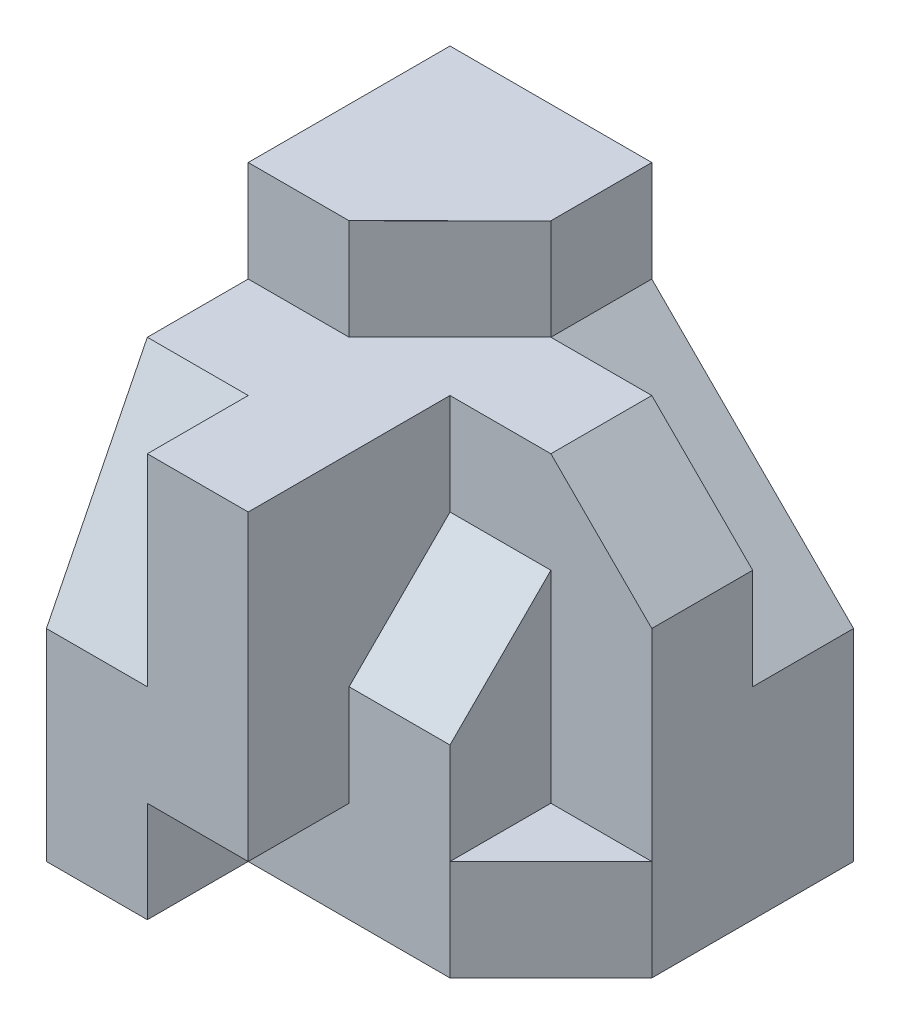
from build123d import *

# Parameters (mm, degrees)
SKETCH1_W           = 4
SKETCH1_H           = 5
BOSS_EXTRUDE1_DEPTH = 4
SKETCH2_OUTSIDE_W   = 7.51
SKETCH2_OUTSIDE_H   = 7.51
CUT_EXTRUDE1_DEPTH  = 1
CUT_EXTRUDE2_DEPTH  = 1
CUT_EXTRUDE3_DEPTH  = 1
CUT_EXTRUDE4_DEPTH  = 5
CUT_EXTRUDE5_DEPTH  = 1
SKETCH7_W           = 2
SKETCH7_H           = 1
CUT_EXTRUDE6_DEPTH  = 1
CUT_EXTRUDE7_DEPTH  = 2
SKETCH9_W           = 1
SKETCH9_H           = 1
CUT_EXTRUDE9_DEPTH  = 3
CUT_EXTRUDE10_DEPTH = 3


with BuildPart() as part:
    # Sketch1 → Boss-Extrude1 (new body)
    with BuildSketch(Plane.XY):
        Rectangle(SKETCH1_W, SKETCH1_H)
    extrude(amount=BOSS_EXTRUDE1_DEPTH)

    # Sketch2 outside → Cut-Extrude1 (cut)
    with BuildSketch(Plane(origin=(0, 2.5, 0), x_dir=(1, 0, 0), z_dir=(0, 1, 0))):
        with Locations((0, -2)):
            Rectangle(SKETCH2_OUTSIDE_W, SKETCH2_OUTSIDE_H)
        Polygon((0, 0), (0, -1), (-1, -2), (-2, -2), (-2, 0), align=None, mode=Mode.SUBTRACT)
    extrude(amount=-CUT_EXTRUDE1_DEPTH, mode=Mode.SUBTRACT)

    # Sketch3 → Cut-Extrude2 (cut)
    with BuildSketch(Plane(origin=(0, 0, 0), x_dir=(-1, 0, 0), z_dir=(0, 0, -1))):
        Polygon((0, 1.5), (-2, -0.5), (-2, 1.5), align=None)
    extrude(amount=-CUT_EXTRUDE2_DEPTH, mode=Mode.SUBTRACT)

    # Sketch4 → Cut-Extrude3 (cut)
    with BuildSketch(Plane.ZY.offset(2)):
        Polygon((3, 1.5), (4, -0.5), (4, 1.5), align=None)
    extrude(amount=-CUT_EXTRUDE3_DEPTH, mode=Mode.SUBTRACT)

    # Sketch5 → Cut-Extrude4 (cut, through all)
    with BuildSketch(Plane.XY.offset(4)):
        Polygon((2, 1.5), (1, 1.5), (2, 0.5), align=None)
    extrude(amount=-CUT_EXTRUDE4_DEPTH, mode=Mode.SUBTRACT)

    # Sketch6 → Cut-Extrude5 (cut)
    with BuildSketch(Plane.XY.offset(4)):
        Polygon((-1, -2.5), (-1, -1.5), (0, -1.5), (0, 1.5), (1, 1.5), (2, 0.5), (2, -2.5), align=None)
    extrude(amount=-CUT_EXTRUDE5_DEPTH, mode=Mode.SUBTRACT)

    # Sketch7 → Cut-Extrude6 (cut)
    with BuildSketch(Plane(origin=(0, 1.5, 0), x_dir=(1, 0, 0), z_dir=(0, 1, 0))):
        with Locations((1, -2.5)):
            Rectangle(SKETCH7_W, SKETCH7_H)
    extrude(amount=-CUT_EXTRUDE6_DEPTH, mode=Mode.SUBTRACT)

    # Sketch8 → Cut-Extrude7 (cut)
    with BuildSketch(Plane(origin=(2, 0, 0), x_dir=(0, 0, -1), z_dir=(1, 0, 0))):
        Polygon((-2, 0.5), (-3, -0.5), (-3, 0.5), align=None)
    extrude(amount=-CUT_EXTRUDE7_DEPTH, mode=Mode.SUBTRACT)

    # Sketch9 → Cut-Extrude9 (cut)
    with BuildSketch(Plane(origin=(0, 1.5, 0), x_dir=(1, 0, 0), z_dir=(0, 1, 0))):
        with Locations((1.5, -2.5)):
            Rectangle(SKETCH9_W, SKETCH9_H)
    extrude(amount=-CUT_EXTRUDE9_DEPTH, mode=Mode.SUBTRACT)

    # Sketch10 → Cut-Extrude10 (cut)
    with BuildSketch(Plane(origin=(0, -1.5, 0), x_dir=(1, 0, 0), z_dir=(0, 1, 0))):
        Polygon((2, -2), (1, -3), (2, -3), align=None)
    extrude(amount=-CUT_EXTRUDE10_DEPTH, mode=Mode.SUBTRACT)


solid = part.part
